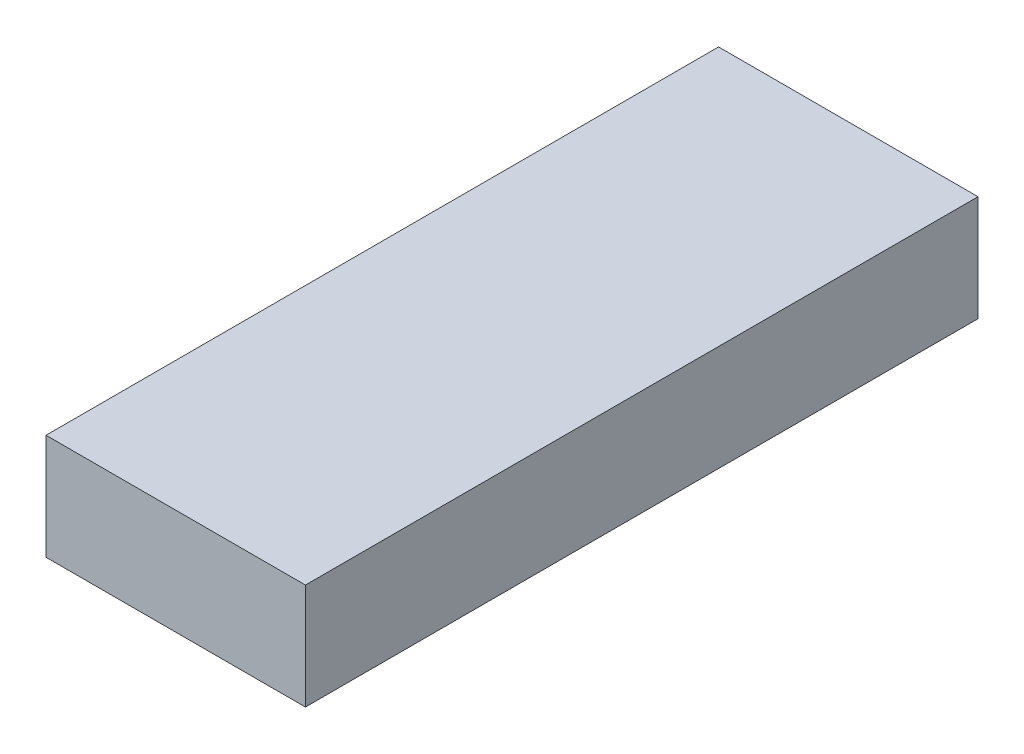
from build123d import *

# Parameters (mm, degrees)
SKETCH1_W           = 27
SKETCH1_H           = 70
BOSS_EXTRUDE1_DEPTH = 11


with BuildPart() as part:
    # Sketch1 → Boss-Extrude1 (new body)
    with BuildSketch(Plane(origin=(0, 0, 0), x_dir=(1, 0, 0), z_dir=(0, 1, 0))):
        Rectangle(SKETCH1_W, SKETCH1_H)
    extrude(amount=BOSS_EXTRUDE1_DEPTH)


solid = part.part
